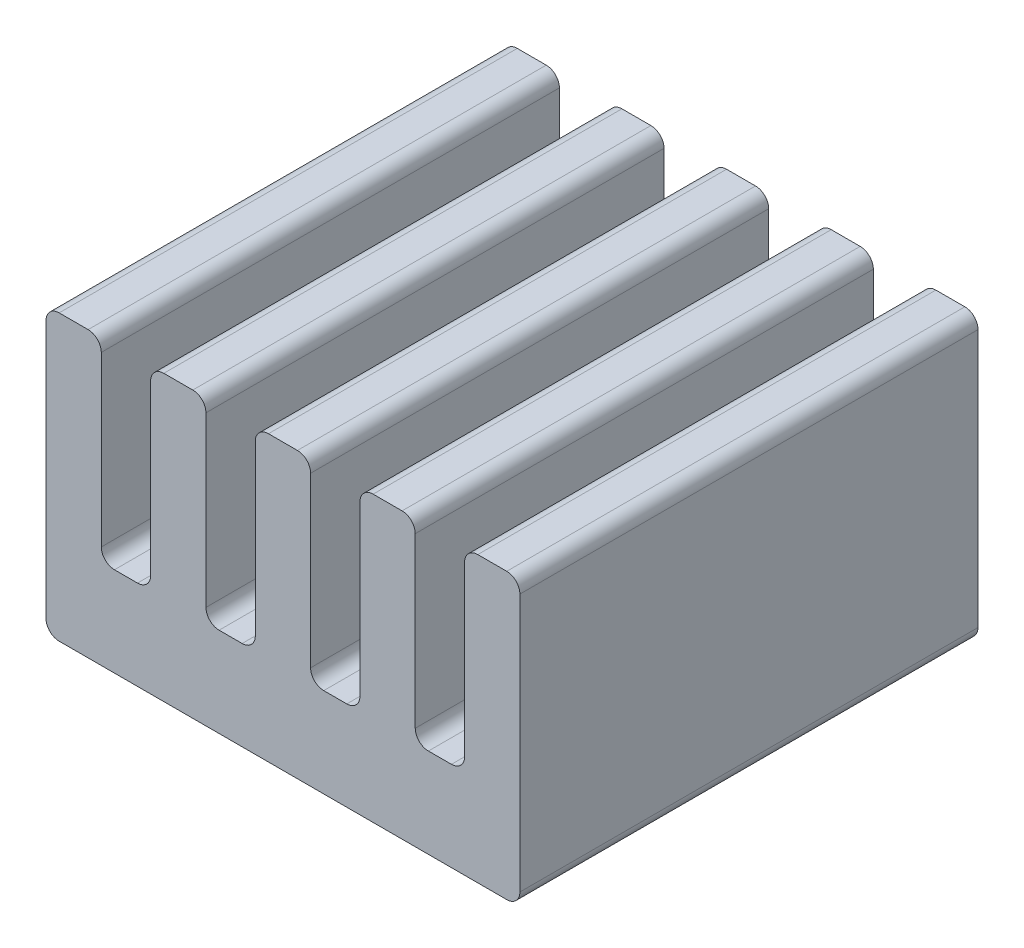
from build123d import *

# Parameters (mm, degrees)
BOSS_EXTRUDE1_DEPTH = 4.35
FILLET1_R           = 0.25


with BuildPart() as part:
    # Sketch1 → Boss-Extrude1 (new body, symmetric)
    with BuildSketch(Plane.XY):
        Polygon((-4.5, 2.7), (-4.5, -2.7), (4.5, -2.7), (4.5, 2.7), (3.45, 2.7), (3.45, -1), (2.5125, -1), (2.5125, 2.7), (1.4625, 2.7), (1.4625, -1), (0.525, -1), (0.525, 2.7), (-0.525, 2.7), (-0.525, -1), (-1.4625, -1), (-1.4625, 2.7), (-2.5125, 2.7), (-2.5125, -1), (-3.45, -1), (-3.45, 2.7), align=None)
    extrude(amount=BOSS_EXTRUDE1_DEPTH, both=True)

    # Fillet1
    fillet1_edges = [part.edges().sort_by_distance(p)[0] for p in [
        (-3.45, 2.7, 0),
        (-3.45, -1, 0),
        (-2.5125, -1, 0),
        (-2.5125, 2.7, 0),
        (-1.4625, 2.7, 0),
        (-1.4625, -1, 0),
        (-0.525, -1, 0),
        (-0.525, 2.7, 0),
        (0.525, 2.7, 0),
        (0.525, -1, 0),
        (1.4625, -1, 0),
        (1.4625, 2.7, 0),
        (2.5125, 2.7, 0),
        (2.5125, -1, 0),
        (3.45, -1, 0),
        (3.45, 2.7, 0),
        (4.5, 2.7, 0),
        (4.5, -2.7, 0),
        (-4.5, -2.7, 0),
        (-4.5, 2.7, 0),
    ]]
    fillet(fillet1_edges, radius=FILLET1_R)


solid = part.part
